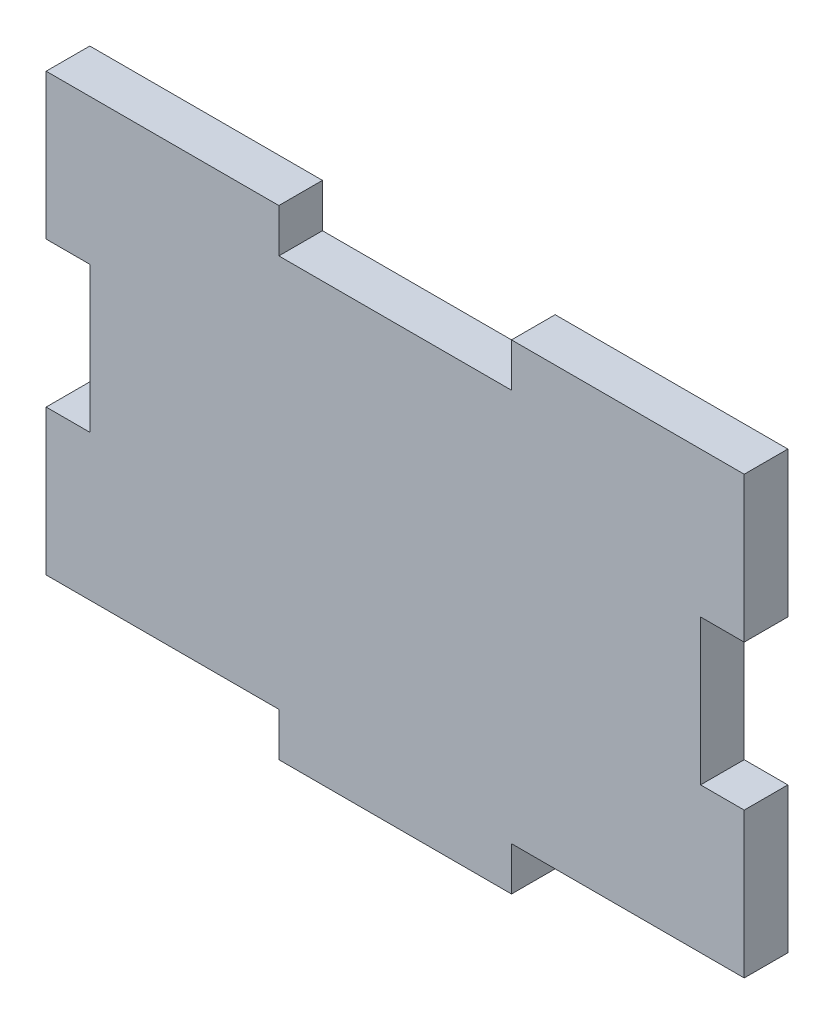
from build123d import *

# Parameters (mm, degrees)
SALIENTE_EXTRUIR1_DEPTH = 5
CROQUIS2_W              = 26.666666666
CROQUIS2_H              = 5
CORTAR_EXTRUIR1_DEPTH   = 10


with BuildPart() as part:
    # Croquis1 → Saliente-Extruir1 (new body)
    with BuildSketch(Plane.XY):
        Polygon((0, 21.666666667), (0, 5), (26.666666667, 5), (26.666666667, 0), (53.333333333, 0), (53.333333333, 5), (80, 5), (80, 21.666666667), (75, 21.666666667), (75, 38.333333333), (80, 38.333333333), (80, 55), (0, 55), (0, 38.333333333), (5, 38.333333333), (5, 21.666666667), align=None)
    extrude(amount=SALIENTE_EXTRUIR1_DEPTH)

    # Croquis2 → Cortar-Extruir1 (cut)
    with BuildSketch(Plane.XY.offset(5)):
        with Locations((40, 52.5)):
            Rectangle(CROQUIS2_W, CROQUIS2_H)
    extrude(amount=-CORTAR_EXTRUIR1_DEPTH, mode=Mode.SUBTRACT)


solid = part.part
